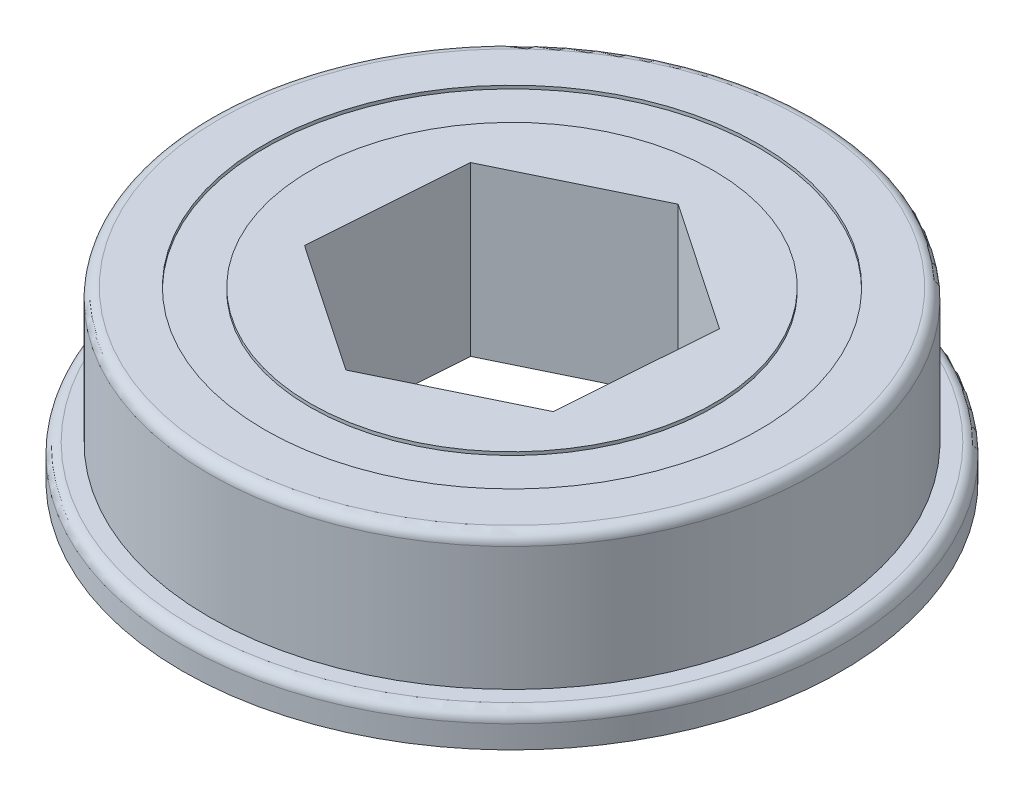
from build123d import *

# Parameters (mm, degrees)
SKETCH1_R                = 9.525
BOSS_EXTRUDE1_DEPTH      = 7.9248
BOSS_EXTRUDE2_DEPTH      = 3.81
BOSS_EXTRUDE2_DEPTH_BACK = 3.81
SKETCH2_R                = 11.67450685
SKETCH2_R_2              = 9.525
SKETCH3_R                = 14.2875
SKETCH3_R_2              = 11.67450685
BOSS_EXTRUDE4_DEPTH      = 7.9248
SKETCH4_R                = 15.56004
SKETCH4_R_2              = 14.2875
BOSS_EXTRUDE5_DEPTH      = 1.5748
FILLET1_R                = 0.508


with BuildPart() as part:
    # Sketch1 → Boss-Extrude1 (new body)
    with BuildSketch(Plane(origin=(0, 0, 0), x_dir=(1, 0, 0), z_dir=(0, 1, 0))):
        Circle(SKETCH1_R)
        Polygon((6.069005203, -4.114669997), (6.597911347, 3.198577683), (0.528906144, 7.31324768), (-6.069005203, 4.114669997), (-6.597911347, -3.198577683), (-0.528906144, -7.31324768), align=None, mode=Mode.SUBTRACT)
    extrude(amount=BOSS_EXTRUDE1_DEPTH)



with BuildPart() as body_2:
    # Sketch2 → Boss-Extrude2 (new, two sides: drawn at the far end of the back side and taken through both)
    with BuildSketch(Plane(origin=(0, 3.9624, 0), x_dir=(1, 0, 0), z_dir=(0, 1, 0)).offset(-BOSS_EXTRUDE2_DEPTH_BACK)):
        Circle(SKETCH2_R)
        Circle(SKETCH2_R_2, mode=Mode.SUBTRACT)
    extrude(amount=BOSS_EXTRUDE2_DEPTH + BOSS_EXTRUDE2_DEPTH_BACK)


with BuildPart() as part_1:
    add(part.part)

    add(body_2.part)  # Boss-Extrude4 merges body 2
    # Sketch3 → Boss-Extrude4 (add)
    with BuildSketch(Plane(origin=(0, 0, 0), x_dir=(1, 0, 0), z_dir=(0, 1, 0))):
        Circle(SKETCH3_R)
        Circle(SKETCH3_R_2, mode=Mode.SUBTRACT)
    extrude(amount=BOSS_EXTRUDE4_DEPTH)

    # Sketch4 → Boss-Extrude5 (add)
    with BuildSketch(Plane(origin=(0, 0, 0), x_dir=(1, 0, 0), z_dir=(0, 1, 0))):
        Circle(SKETCH4_R)
        Circle(SKETCH4_R_2, mode=Mode.SUBTRACT)
    extrude(amount=BOSS_EXTRUDE5_DEPTH)

    # Fillet1
    fillet1_edges = [part_1.edges().sort_by_distance(p)[0] for p in [
        (-15.56004, 1.5748, 0),
        (-14.2875, 7.9248, 0),
    ]]
    fillet(fillet1_edges, radius=FILLET1_R)


solid = part_1.part
